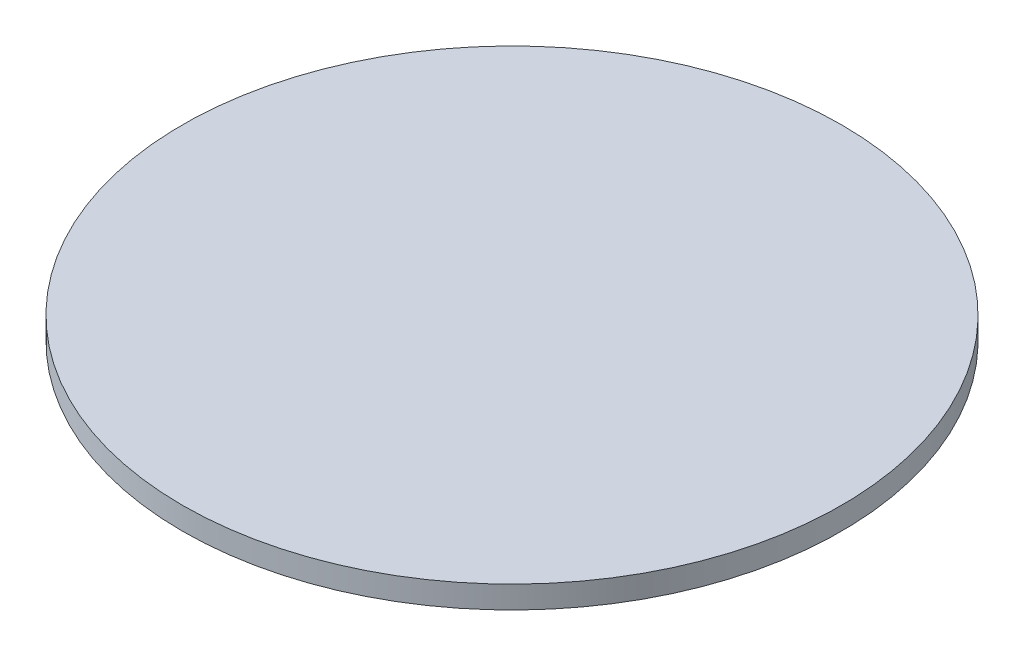
from build123d import *

# Parameters (mm, degrees)
SKETCH1_R           = 11.75
BOSS_EXTRUDE1_DEPTH = 0.8


with BuildPart() as part:
    # Sketch1 → Boss-Extrude1 (new body)
    with BuildSketch(Plane(origin=(0, 0, 0), x_dir=(1, 0, 0), z_dir=(0, 1, 0))):
        Circle(SKETCH1_R)
    extrude(amount=BOSS_EXTRUDE1_DEPTH)


solid = part.part
